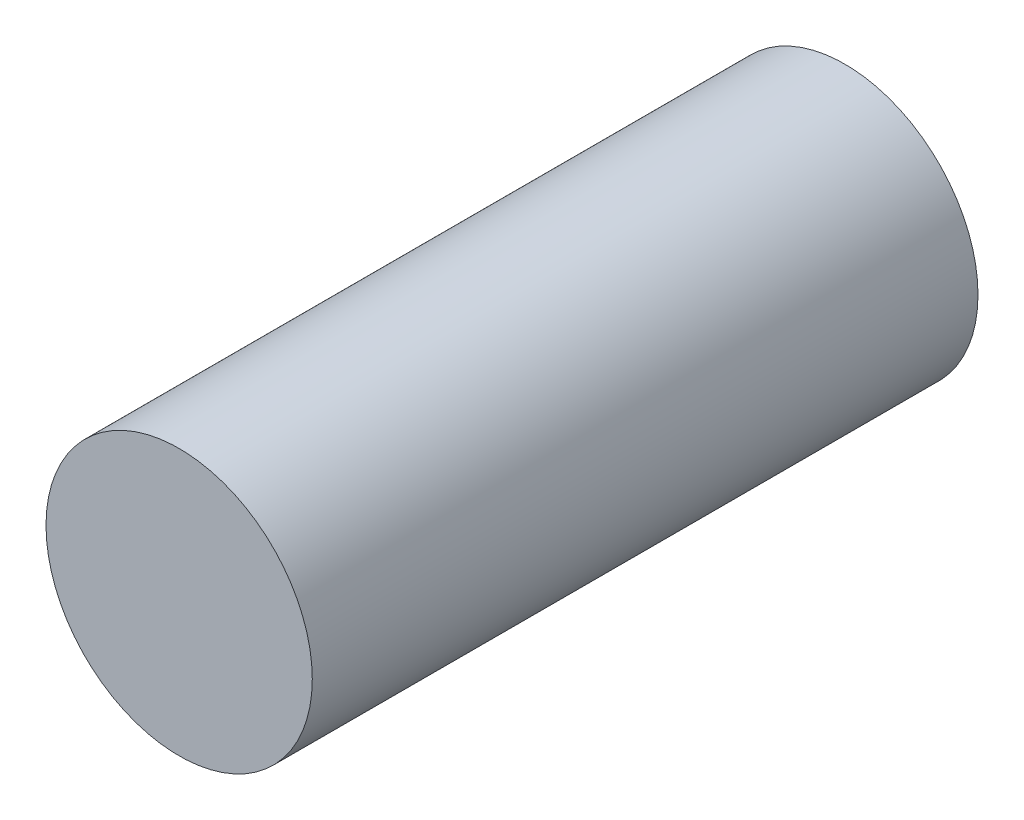
from build123d import *

# Parameters (mm, degrees)
CROQUIS1_R              = 5
SALIENTE_EXTRUIR1_DEPTH = 25


with BuildPart() as part:
    # Croquis1 → Saliente-Extruir1 (new body)
    with BuildSketch(Plane.XY):
        Circle(CROQUIS1_R)
    extrude(amount=SALIENTE_EXTRUIR1_DEPTH)


solid = part.part
